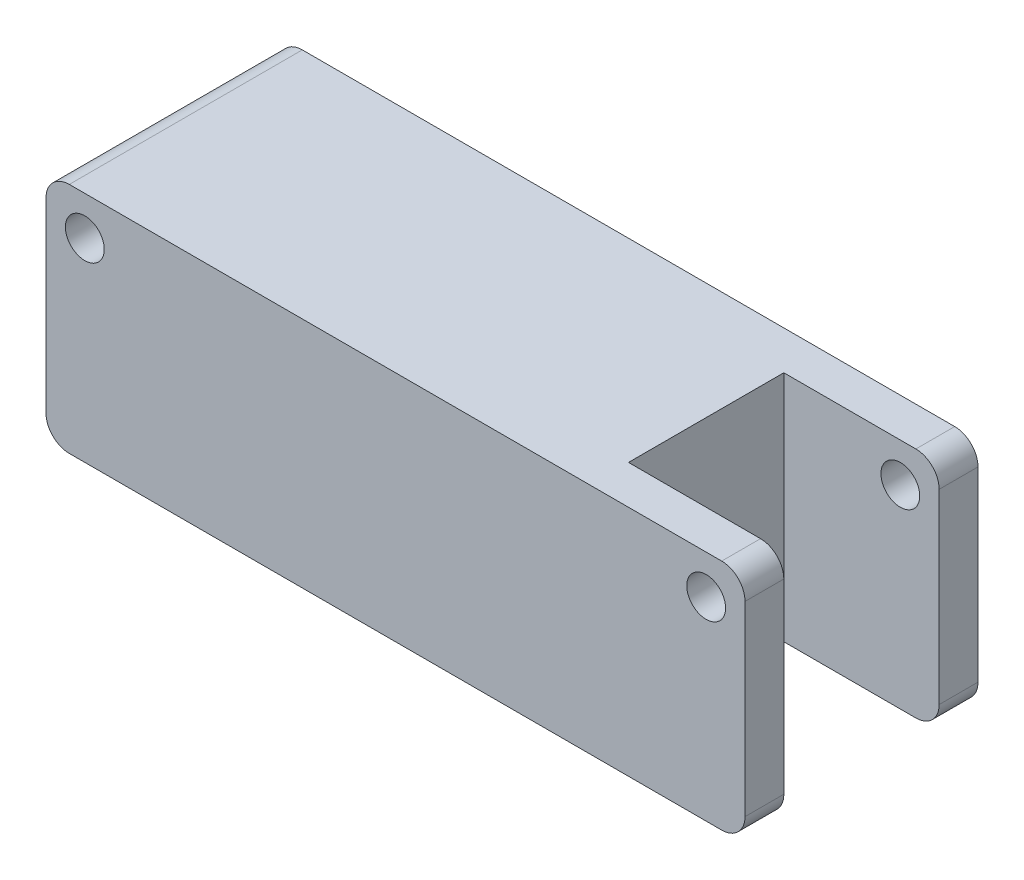
from build123d import *

# Parameters (mm, degrees)
ESQUISSE2_W             = 90
ESQUISSE2_H             = 30
BOSS_EXTRU_1_DEPTH      = 15
CONG_1_R                = 3
ESQUISSE4_W             = 20
ESQUISSE4_H             = 20
ENL_V_MAT_EXTRU_1_DEPTH = 97.046863561
ESQUISSE5_R             = 2.5
ENL_V_MAT_EXTRU_2_DEPTH = 97.046863561


with BuildPart() as part:
    # Esquisse2 → Boss.-Extru.1 (new, symmetric)
    with BuildSketch(Plane(origin=(0, 0, 0), x_dir=(1, 0, 0), z_dir=(0, 1, 0))):
        with Locations((45, 0)):
            Rectangle(ESQUISSE2_W, ESQUISSE2_H)
    extrude(amount=BOSS_EXTRU_1_DEPTH, both=True)

    # Congé1
    cong_1_edges = [part.edges().sort_by_distance(p)[0] for p in [
        (0, 15, 0),
        (90, 15, 0),
        (90, -15, 0),
        (0, -15, 0),
    ]]
    fillet(cong_1_edges, radius=CONG_1_R)

    # Esquisse4 → Enlèv. mat.-Extru.1 (cut, through all)
    with BuildSketch(Plane(origin=(0, 15, 0), x_dir=(1, 0, 0), z_dir=(0, 1, 0))):
        with Locations((80, 0)):
            Rectangle(ESQUISSE4_W, ESQUISSE4_H)
    extrude(amount=-ENL_V_MAT_EXTRU_1_DEPTH, mode=Mode.SUBTRACT)

    # Esquisse5 → Enlèv. mat.-Extru.2 (cut, through all)
    with BuildSketch(Plane(origin=(0, 0, -15), x_dir=(-1, 0, 0), z_dir=(0, 0, -1))):
        with Locations((-85, 10)):
            Circle(ESQUISSE5_R)
        with Locations((-5, 10)):
            Circle(ESQUISSE5_R)
    extrude(amount=-ENL_V_MAT_EXTRU_2_DEPTH, mode=Mode.SUBTRACT)


solid = part.part
